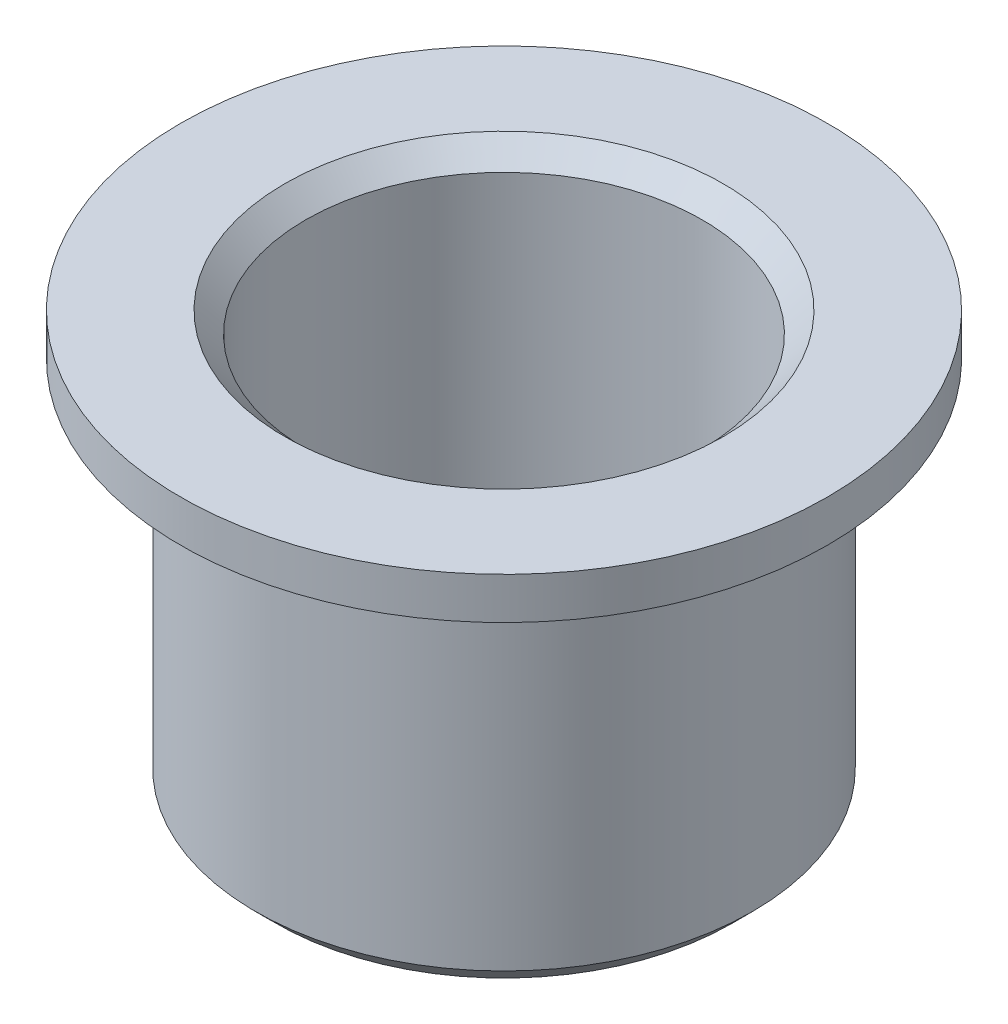
from build123d import *


with BuildPart() as part:
    # Sketch1 → Revolve1 (revolve)
    with BuildSketch(Plane.XY):
        Polygon((4.75, 9.5), (4.75, 0), (5.45, 0), (5.95, 0.5), (5.95, 7.960769515), (7.75, 9), (7.75, 10), (5.25, 10), align=None)
    revolve(axis=Axis((0, -12.923275862, 0), (0, 1, 0)))


solid = part.part
